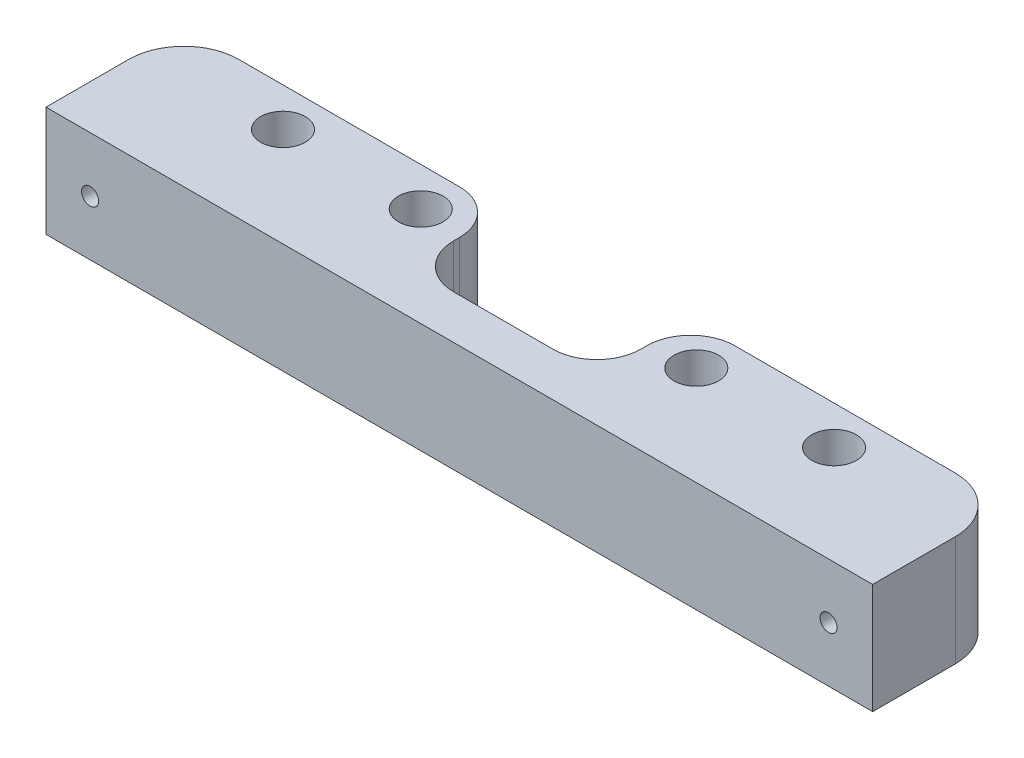
from build123d import *

# Parameters (mm, degrees)
SKETCH1_W           = 150
SKETCH1_H           = 25
SKETCH1_R           = 4.05
BOSS_EXTRUDE1_DEPTH = 20
FILLET1_R           = 10
SKETCH3_R           = 1.55
CUT_EXTRUDE1_DEPTH  = 26
SKETCH3_3_R         = 3.5
SKETCH3_3_R_2       = 1.55
CUT_EXTRUDE2_DEPTH  = 3
SKETCH4_W           = 34
SKETCH4_H           = 34.075617562
CUT_EXTRUDE3_DEPTH  = 21.0000001
FILLET2_R           = 8


with BuildPart() as part:
    # Sketch1 → Boss-Extrude1 (new body)
    with BuildSketch(Plane(origin=(0, 0, 0), x_dir=(1, 0, 0), z_dir=(0, 1, 0))):
        Rectangle(SKETCH1_W, SKETCH1_H)
        with Locations(Location((-25, 5.5, 0), (0, 0, 270))):  # turned: the seam where the file's is
            Circle(SKETCH1_R, mode=Mode.SUBTRACT)
        with Locations(Location((25, 5.5, 0), (0, 0, 270))):  # turned: the seam where the file's is
            Circle(SKETCH1_R, mode=Mode.SUBTRACT)
        with Locations(Location((-50, 5.5, 0), (0, 0, 270))):  # turned: the seam where the file's is
            Circle(SKETCH1_R, mode=Mode.SUBTRACT)
        with Locations(Location((50, 5.5, 0), (0, 0, 270))):  # turned: the seam where the file's is
            Circle(SKETCH1_R, mode=Mode.SUBTRACT)
    extrude(amount=BOSS_EXTRUDE1_DEPTH)

    # Fillet1
    fillet1_edges = [part.edges().sort_by_distance(p)[0] for p in [
        (-75, 10, -12.5),
        (75, 10, -12.5),
    ]]
    fillet(fillet1_edges, radius=FILLET1_R)

    # Sketch3 → Cut-Extrude1 (cut, through all)
    with BuildSketch(Plane(origin=(0, 0, -12.5), x_dir=(-1, 0, 0), z_dir=(0, 0, -1))):
        with Locations((-67, 10)):
            Circle(SKETCH3_R)
        with Locations((67, 10)):
            Circle(SKETCH3_R)
    extrude(amount=-CUT_EXTRUDE1_DEPTH, mode=Mode.SUBTRACT)

    # Sketch3_3 → Cut-Extrude2 (cut)
    with BuildSketch(Plane(origin=(0, 0, -12.5), x_dir=(-1, 0, 0), z_dir=(0, 0, -1))):
        with Locations((-67, 10)):
            Circle(SKETCH3_3_R)
        with Locations((-67, 10)):
            Circle(SKETCH3_3_R_2, mode=Mode.SUBTRACT)
        with Locations((67, 10)):
            Circle(SKETCH3_3_R)
        with Locations((67, 10)):
            Circle(SKETCH3_3_R_2, mode=Mode.SUBTRACT)
    extrude(amount=-CUT_EXTRUDE2_DEPTH, mode=Mode.SUBTRACT)

    # Sketch4 → Cut-Extrude3 (cut, through all)
    with BuildSketch(Plane(origin=(0, 20, 0), x_dir=(1, 0, 0), z_dir=(0, 1, 0))):
        with Locations((0, 12.5)):
            Rectangle(SKETCH4_W, SKETCH4_H)
    extrude(amount=-CUT_EXTRUDE3_DEPTH, mode=Mode.SUBTRACT)

    # Fillet2
    fillet2_edges = [part.edges().sort_by_distance(p)[0] for p in [
        (-17, 10, -12.5),
        (17, 10, -12.5),
        (-17, 10, 4.537808781),
        (17, 10, 4.537808781),
    ]]
    fillet(fillet2_edges, radius=FILLET2_R)


solid = part.part
